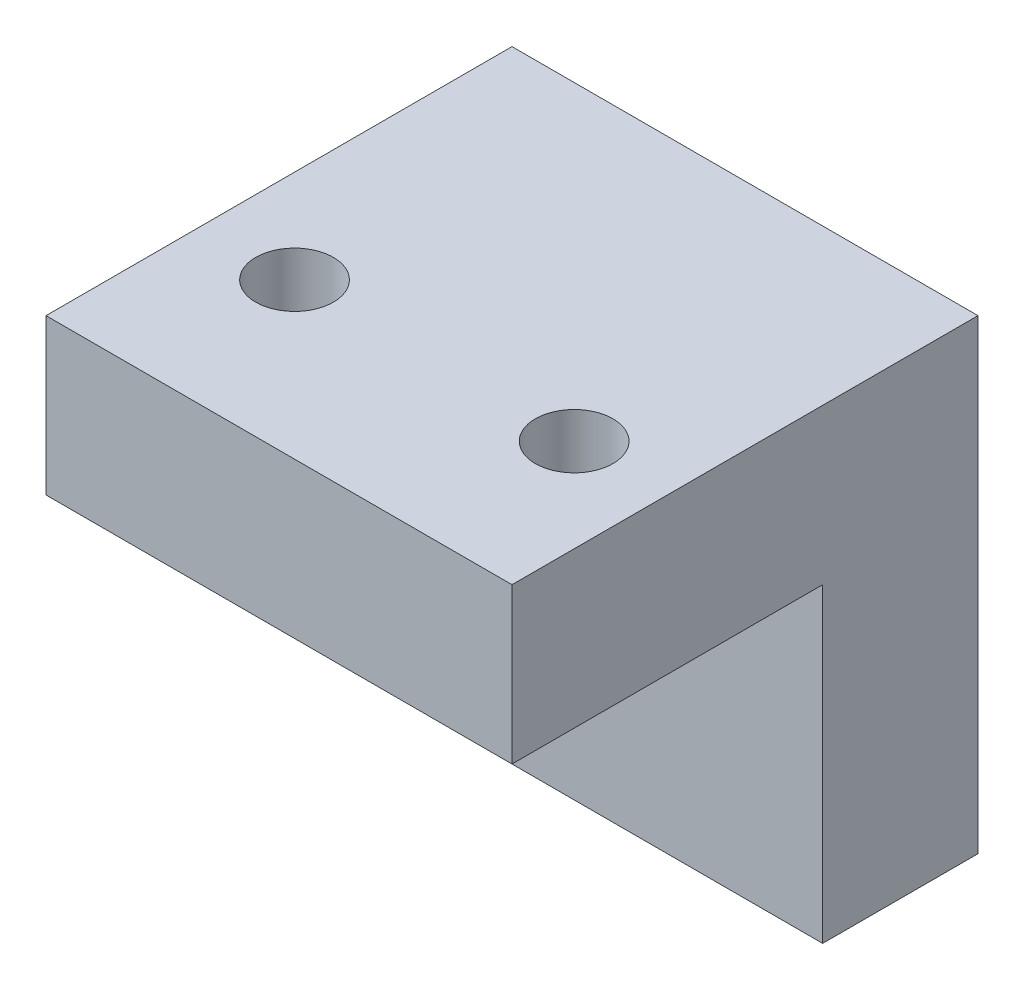
from build123d import *

# Parameters (mm, degrees)
SKETCH_1_W          = 15
SKETCH_1_H          = 5
EXTRUDE_1_DEPTH     = 10
SKETCH_2_W          = 15
SKETCH_2_H          = 15
EXTRUDE_2_DEPTH     = 5
SKETCH_3_R          = 1.25
CUT_EXTRUDE_1_DEPTH = 6
SKETCH_4_R          = 1.25
CUT_EXTRUDE_2_DEPTH = 5


with BuildPart() as part:
    # 草图1 → 凸台-拉伸1 (new body)
    with BuildSketch(Plane(origin=(0, 0, 0), x_dir=(1, 0, 0), z_dir=(0, 1, 0))):
        with Locations((7.5, 2.5)):
            Rectangle(SKETCH_1_W, SKETCH_1_H)
    extrude(amount=EXTRUDE_1_DEPTH)

    # 草图2 → 凸台-拉伸2 (add)
    with BuildSketch(Plane(origin=(0, 10, 0), x_dir=(1, 0, 0), z_dir=(0, 1, 0))):
        with Locations((7.5, -2.5)):
            Rectangle(SKETCH_2_W, SKETCH_2_H)
    extrude(amount=EXTRUDE_2_DEPTH)

    # 草图3 → 切除-拉伸1 (cut, through all)
    with BuildSketch(Plane.XY):
        with Locations((7.5, 5)):
            Circle(SKETCH_3_R)
    extrude(amount=-CUT_EXTRUDE_1_DEPTH, mode=Mode.SUBTRACT)

    # 草图4 → 切除-拉伸2 (cut)
    with BuildSketch(Plane(origin=(0, 15, 0), x_dir=(1, 0, 0), z_dir=(0, 1, 0))):
        with Locations((3, -5)):
            Circle(SKETCH_4_R)
        with Locations((12, -5)):
            Circle(SKETCH_4_R)
    extrude(amount=-CUT_EXTRUDE_2_DEPTH, mode=Mode.SUBTRACT)


solid = part.part
